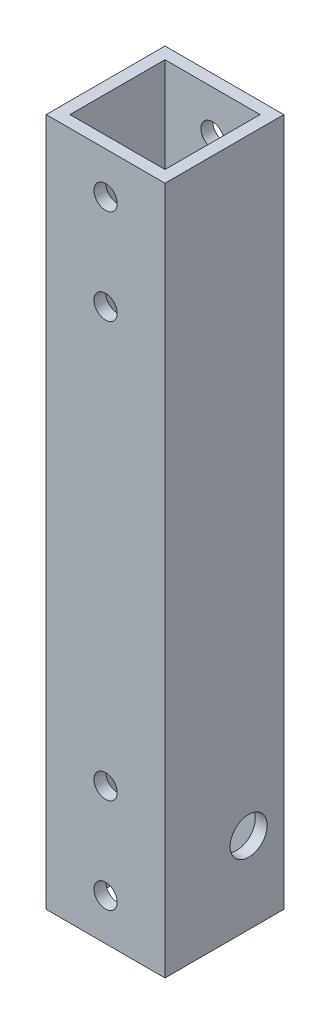
from build123d import *

# Parameters (mm, degrees)
SKETCH1_W           = 25.4
SKETCH1_H           = 147.155789
BOSS_EXTRUDE1_DEPTH = 25.4
SKETCH2_W           = 20.32
SKETCH2_H           = 20.32
CUT_EXTRUDE1_DEPTH  = 152.476553421
SKETCH3_R           = 2.4892
CUT_EXTRUDE2_DEPTH  = 152.476553421
SKETCH5_R           = 3.9624
CUT_EXTRUDE3_DEPTH  = 152.476553421


with BuildPart() as part:
    # Sketch1 → Boss-Extrude1 (new body)
    with BuildSketch(Plane.XY):
        with Locations((12.7, 73.5778945)):
            Rectangle(SKETCH1_W, SKETCH1_H)
    extrude(amount=BOSS_EXTRUDE1_DEPTH)

    # Sketch2 → Cut-Extrude1 (cut, through all)
    with BuildSketch(Plane(origin=(0, 147.155789, 0), x_dir=(1, 0, 0), z_dir=(0, 1, 0))):
        with Locations((12.7, -12.7)):
            Rectangle(SKETCH2_W, SKETCH2_H)
    extrude(amount=-CUT_EXTRUDE1_DEPTH, mode=Mode.SUBTRACT)

    # Sketch3 → Cut-Extrude2 (cut, through all)
    with BuildSketch(Plane(origin=(0, 0, 0), x_dir=(-1, 0, 0), z_dir=(0, 0, -1))):
        with Locations((-12.7, 138.265789)):
            Circle(SKETCH3_R)
        with Locations((-12.7, 117.945789)):
            Circle(SKETCH3_R)
        with Locations((-12.7, 29.21)):
            Circle(SKETCH3_R)
        with Locations((-12.7, 8.89)):
            Circle(SKETCH3_R)
    extrude(amount=-CUT_EXTRUDE2_DEPTH, mode=Mode.SUBTRACT)

    # Sketch5 → Cut-Extrude3 (cut, through all)
    with BuildSketch(Plane(origin=(25.4, 0, 0), x_dir=(0, 0, -1), z_dir=(1, 0, 0))):
        with Locations((-7.5184, 17.3804072)):
            Circle(SKETCH5_R)
    extrude(amount=-CUT_EXTRUDE3_DEPTH, mode=Mode.SUBTRACT)


solid = part.part
